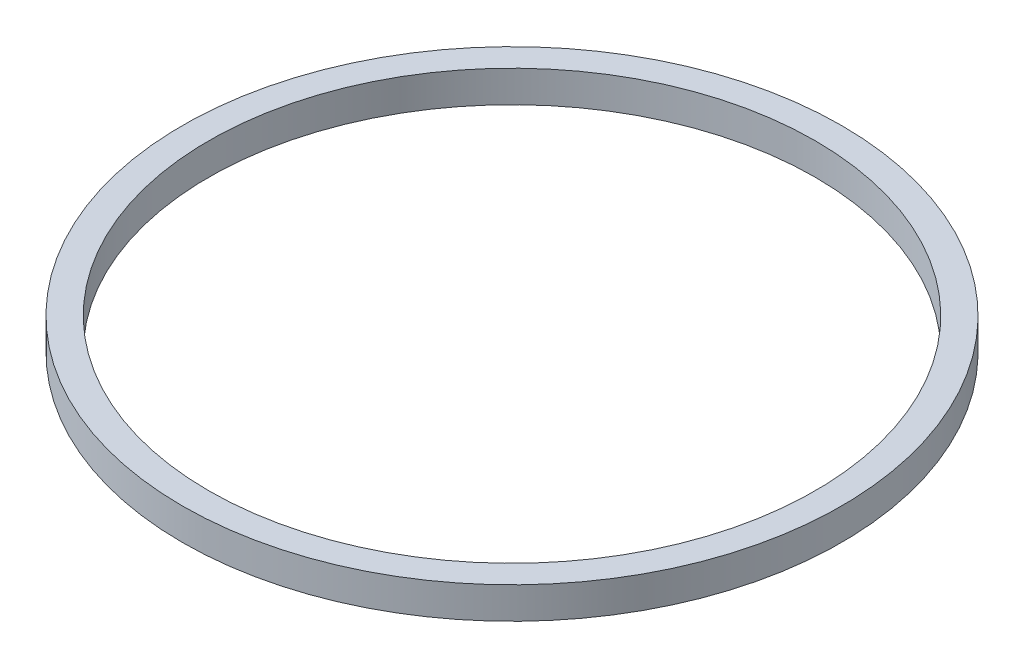
from build123d import *

# Parameters (mm, degrees)
SKETCH_1_R      = 62.5
SKETCH_1_R_2    = 57.5
EXTRUDE_1_DEPTH = 6


with BuildPart() as part:
    # 草图1 → 凸台-拉伸1 (new body)
    with BuildSketch(Plane(origin=(0, 0, 0), x_dir=(1, 0, 0), z_dir=(0, 1, 0))):
        Circle(SKETCH_1_R)
        Circle(SKETCH_1_R_2, mode=Mode.SUBTRACT)
    extrude(amount=EXTRUDE_1_DEPTH)


solid = part.part
